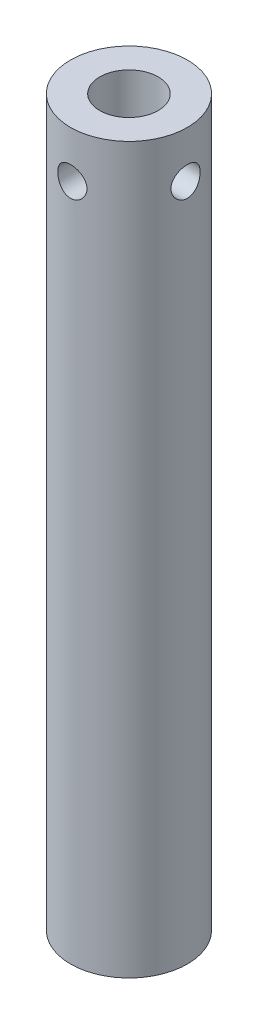
from build123d import *

# Parameters (mm, degrees)
SKETCH1_R              = 5
BOSS_EXTRUDE1_DEPTH    = 62
SKETCH7_R              = 2.5
CUT_EXTRUDE1_DEPTH     = 26
M3_TAPPED_HOLE1_REACH  = 61.068
M3_TAPPED_HOLE1_BORE_R = 1.25
M3_TAPPED_HOLE2_REACH  = 61.068
M3_TAPPED_HOLE2_BORE_R = 1.25


with BuildPart() as part:
    # Sketch1 → Boss-Extrude1 (new body)
    with BuildSketch(Plane(origin=(0, 0, 0), x_dir=(1, 0, 0), z_dir=(0, 1, 0))):
        with Locations(Location((0, 0, 0), (0, 0, 270))):
            Circle(SKETCH1_R)
    extrude(amount=BOSS_EXTRUDE1_DEPTH)

    # Sketch7 → Cut-Extrude1 (cut)
    with BuildSketch(Plane(origin=(0, 62, 0), x_dir=(1, 0, 0), z_dir=(0, 1, 0))):
        with Locations(Location((0, 0, 0), (0, 0, 270))):
            Circle(SKETCH7_R)
    extrude(amount=-CUT_EXTRUDE1_DEPTH, mode=Mode.SUBTRACT)

    # M3 Tapped Hole1 bore (on position points) → M3 Tapped Hole1 (cut, up to next)
    with BuildSketch(Plane(origin=(0, 58, 5), x_dir=(1, 0, 0), z_dir=(0, 0, 1)), mode=Mode.PRIVATE) as m3_tapped_hole1_sk1:
        Circle(M3_TAPPED_HOLE1_BORE_R)
    m3_tapped_hole1_tool1 = extrude(m3_tapped_hole1_sk1.sketch, amount=-M3_TAPPED_HOLE1_REACH, mode=Mode.PRIVATE) & part.part
    add(m3_tapped_hole1_tool1.solids().sort_by_distance((0, 58, 5))[0], mode=Mode.SUBTRACT)

    # M3 Tapped Hole2 bore (on position points) → M3 Tapped Hole2 (cut, up to next)
    with BuildSketch(Plane(origin=(5, 58, 0), x_dir=(0, 0, 1), z_dir=(1, 0, 0)), mode=Mode.PRIVATE) as m3_tapped_hole2_sk1:
        Circle(M3_TAPPED_HOLE2_BORE_R)
    m3_tapped_hole2_tool1 = extrude(m3_tapped_hole2_sk1.sketch, amount=-M3_TAPPED_HOLE2_REACH, mode=Mode.PRIVATE) & part.part
    add(m3_tapped_hole2_tool1.solids().sort_by_distance((5, 58, 0))[0], mode=Mode.SUBTRACT)


solid = part.part
